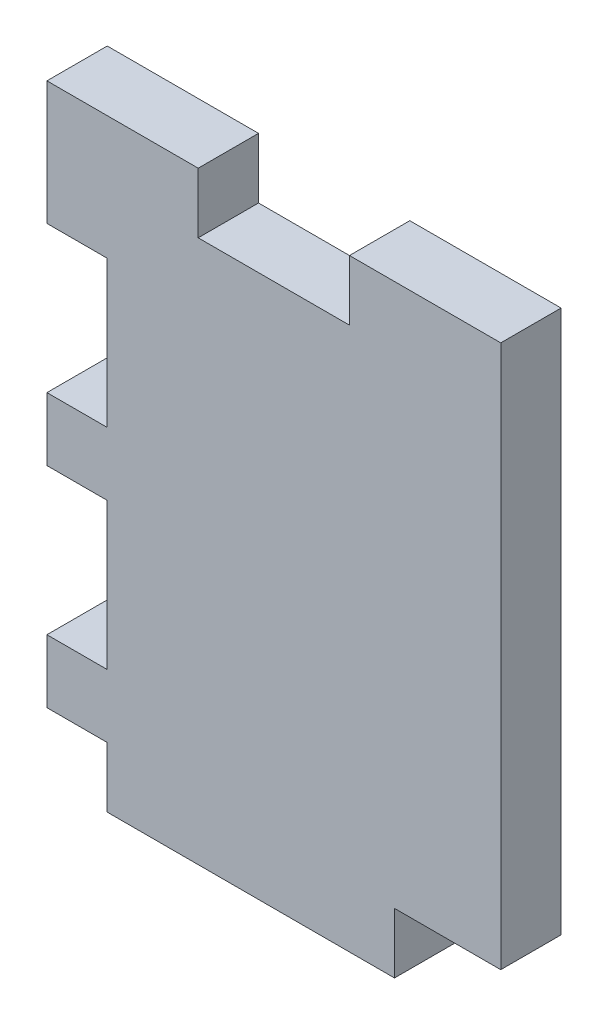
from build123d import *

# Parameters (mm, degrees)
SKETCH1_W           = 40.132
SKETCH1_H           = 53.34
BOSS_EXTRUDE1_DEPTH = 5.334
SKETCH3_W           = 5.334
SKETCH3_H           = 5.334
SKETCH3_W_2         = 9.398
CUT_EXTRUDE1_DEPTH  = 6.334
SKETCH4_W           = 5.334
SKETCH4_H           = 12.954
CUT_EXTRUDE2_DEPTH  = 6.334
SKETCH5_W           = 13.377333334
SKETCH5_H           = 5.334
CUT_EXTRUDE3_DEPTH  = 6.334


with BuildPart() as part:
    # Sketch1 → Boss-Extrude1 (new body)
    with BuildSketch(Plane.XY):
        with Locations((20.066, 26.67)):
            Rectangle(SKETCH1_W, SKETCH1_H)
    extrude(amount=BOSS_EXTRUDE1_DEPTH)

    # Sketch3 → Cut-Extrude1 (cut, through all)
    with BuildSketch(Plane.XY.offset(5.334)):
        with Locations((2.667, 2.667)):
            Rectangle(SKETCH3_W, SKETCH3_H)
        with Locations((35.433, 2.667)):
            Rectangle(SKETCH3_W_2, SKETCH3_H)
    extrude(amount=-CUT_EXTRUDE1_DEPTH, mode=Mode.SUBTRACT)

    # Sketch4 → Cut-Extrude2 (cut, through all)
    with BuildSketch(Plane.XY.offset(5.334)):
        with Locations((2.667, 35.941)):
            Rectangle(SKETCH4_W, SKETCH4_H)
        with Locations((2.667, 17.399)):
            Rectangle(SKETCH4_W, SKETCH4_H)
    extrude(amount=-CUT_EXTRUDE2_DEPTH, mode=Mode.SUBTRACT)

    # Sketch5 → Cut-Extrude3 (cut, through all)
    with BuildSketch(Plane.XY.offset(5.334)):
        with Locations((20.066, 50.673)):
            Rectangle(SKETCH5_W, SKETCH5_H)
    extrude(amount=-CUT_EXTRUDE3_DEPTH, mode=Mode.SUBTRACT)


solid = part.part
